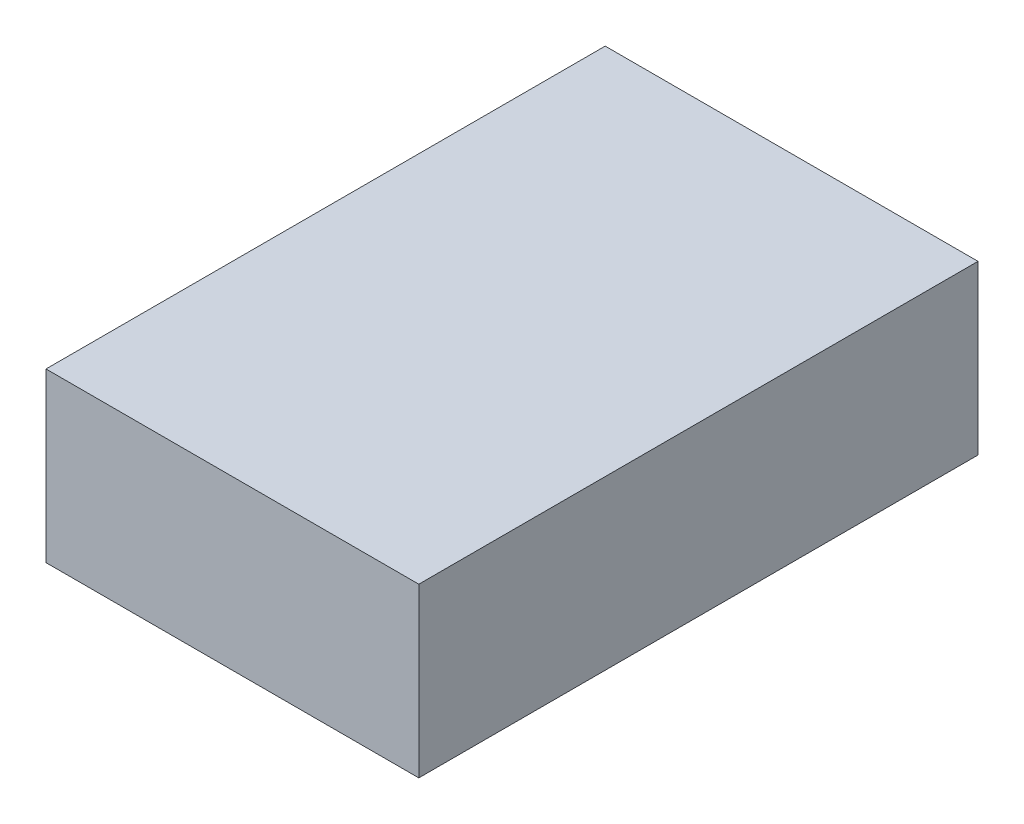
from build123d import *

# Parameters (mm, degrees)
SKETCH1_W           = 2
SKETCH1_H           = 3
BOSS_EXTRUDE1_DEPTH = 0.9


with BuildPart() as part:
    # Sketch1 → Boss-Extrude1 (new body)
    with BuildSketch(Plane(origin=(0, 0, 0), x_dir=(1, 0, 0), z_dir=(0, 1, 0))):
        Rectangle(SKETCH1_W, SKETCH1_H)
    extrude(amount=BOSS_EXTRUDE1_DEPTH)


solid = part.part
